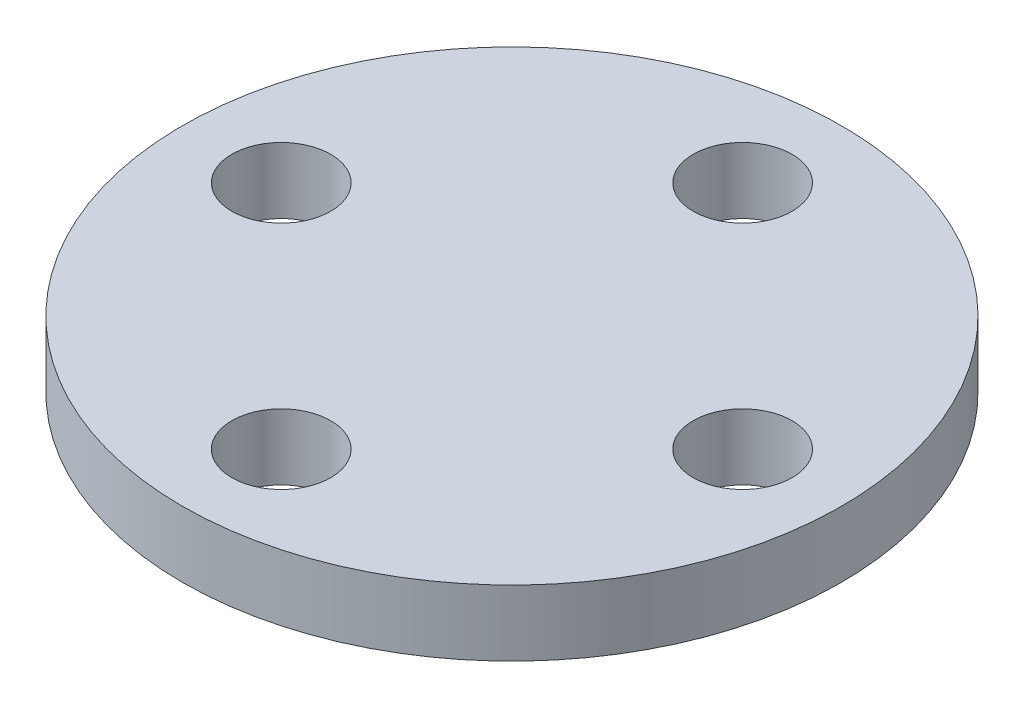
from build123d import *

# Parameters (mm, degrees)
SKETCH1_R           = 10
SKETCH1_R_2         = 1.5
BOSS_EXTRUDE1_DEPTH = 2
SKETCH2_R           = 4
SKETCH2_R_2         = 2
BOSS_EXTRUDE2_DEPTH = 3


with BuildPart() as part:
    # Sketch1 → Boss-Extrude1 (new body)
    with BuildSketch(Plane(origin=(0, 0, 0), x_dir=(1, 0, 0), z_dir=(0, 1, 0))):
        Circle(SKETCH1_R)
        with Locations((0, 7)):
            Circle(SKETCH1_R_2, mode=Mode.SUBTRACT)
        with Locations((7, 0)):
            Circle(SKETCH1_R_2, mode=Mode.SUBTRACT)
        with Locations((0, -7)):
            Circle(SKETCH1_R_2, mode=Mode.SUBTRACT)
        with Locations((-7, 0)):
            Circle(SKETCH1_R_2, mode=Mode.SUBTRACT)
    extrude(amount=BOSS_EXTRUDE1_DEPTH)

    # Sketch2 → Boss-Extrude2 (add)
    with BuildSketch(Plane.XZ):
        Circle(SKETCH2_R)
        Circle(SKETCH2_R_2, mode=Mode.SUBTRACT)
    extrude(amount=BOSS_EXTRUDE2_DEPTH)


solid = part.part
